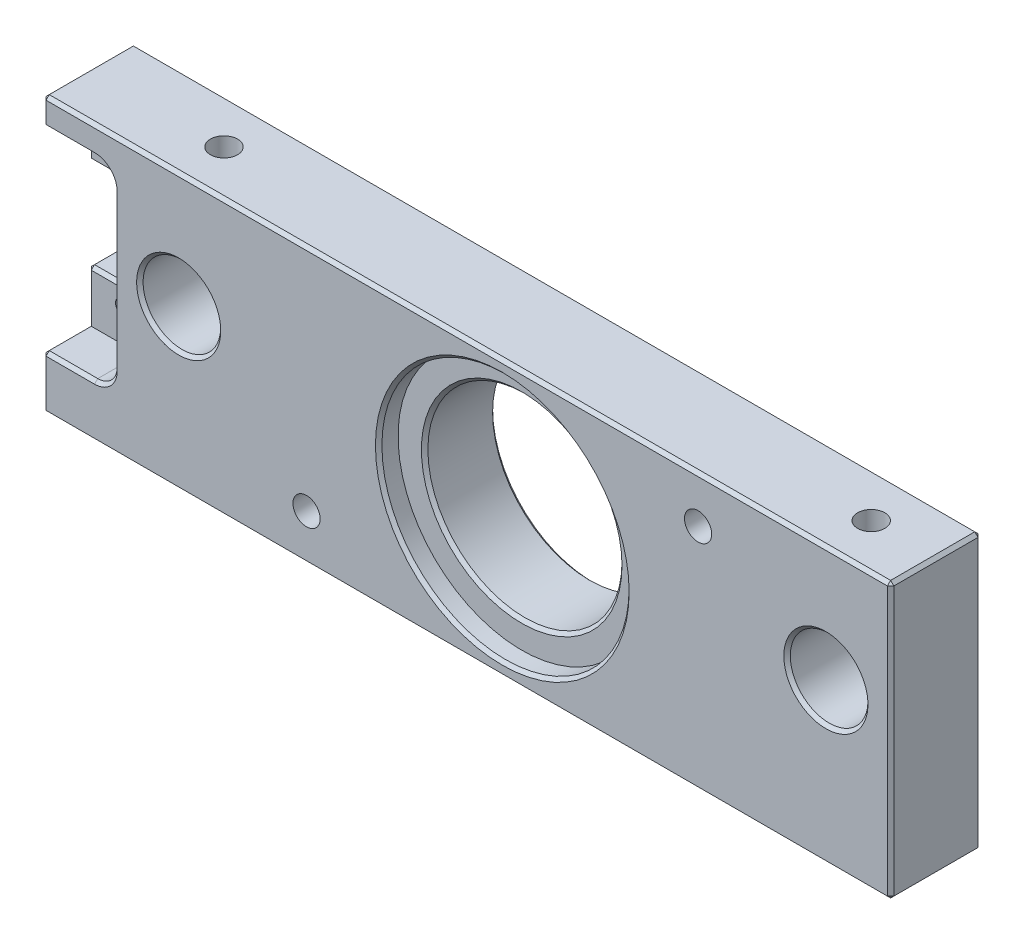
from build123d import *

# Parameters (mm, degrees)
SKETCH1_W                      = 120
SKETCH1_H                      = 42.5
BOSS_EXTRUDE1_DEPTH            = 7
SKETCH2_R                      = 19.1
CUT_EXTRUDE1_DEPTH             = 3
SKETCH3_R                      = 15
CUT_EXTRUDE2_DEPTH             = 65.595375221
M5X0_8_TAPPED_HOLE3_D          = 4.2
M5X0_8_TAPPED_HOLE3_DEPTH      = 14
M5X0_8_TAPPED_HOLE3_TIP        = 1.2618073
SKETCH5_R                      = 6
CUT_EXTRUDE4_DEPTH             = 66.173326599
M5X0_8_TAPPED_HOLE2_AT_2_COUNT = 2
M5X0_8_TAPPED_HOLE2_AT_2_PITCH = 28
SKETCH6_R                      = 1.25
CUT_EXTRUDE5_DEPTH             = 10
M5X0_8_TAPPED_HOLE1_REACH      = 75.86
M5X0_8_TAPPED_HOLE1_BORE_R     = 2.1
SKETCH16_W                     = 14
SKETCH16_H                     = 42.5
BOSS_EXTRUDE2_DEPTH            = 11
SKETCH17_W                     = 11
SKETCH17_H                     = 30
CUT_EXTRUDE6_DEPTH             = 7
M3X0_5_TAPPED_HOLE1_D          = 2.5
SKETCH21_W                     = 10
SKETCH21_H                     = 14
CUT_EXTRUDE7_DEPTH             = 75.441671835
FILLET1_R                      = 3
CHAMFER1_SIZE                  = 0.5


with BuildPart() as part:
    # Sketch1 → Boss-Extrude1 (new, symmetric)
    with BuildSketch(Plane.XY):
        Rectangle(SKETCH1_W, SKETCH1_H)
    extrude(amount=BOSS_EXTRUDE1_DEPTH, both=True)

    # Sketch2 → Cut-Extrude1 (cut)
    with BuildSketch(Plane.XY.offset(7)):
        Circle(SKETCH2_R)
    extrude(amount=-CUT_EXTRUDE1_DEPTH, mode=Mode.SUBTRACT)

    # Sketch3 → Cut-Extrude2 (cut, through all)
    with BuildSketch(Plane.XY.offset(4)):
        Circle(SKETCH3_R)
    extrude(amount=-CUT_EXTRUDE2_DEPTH, mode=Mode.SUBTRACT)

    # M5x0.8 Tapped Hole3
    with Locations(Plane.XY.offset(7)):
        with Locations((-30.248022392, -14.104884486), (30.248022392, 14.104884486)):
            Hole(M5X0_8_TAPPED_HOLE3_D / 2, depth=M5X0_8_TAPPED_HOLE3_DEPTH)
            with Locations((0, 0, -(M5X0_8_TAPPED_HOLE3_DEPTH + M5X0_8_TAPPED_HOLE3_TIP / 2))):  # 118° drill point
                Cone(0, M5X0_8_TAPPED_HOLE3_D / 2, M5X0_8_TAPPED_HOLE3_TIP, mode=Mode.SUBTRACT)

    # Sketch5 → Cut-Extrude4 (cut, through all)
    with BuildSketch(Plane.XY.offset(7)):
        with Locations((-50, 3.4)):
            Circle(SKETCH5_R)
        with Locations((50, 3.4)):
            Circle(SKETCH5_R)
    extrude(amount=-CUT_EXTRUDE4_DEPTH, mode=Mode.SUBTRACT)

    # Sketch10 → M5x0.8 Tapped Hole2 (revolve, cut)
    with BuildSketch(Plane(origin=(-50, -21.25, 0), x_dir=(0, 0, -1), z_dir=(1, 0, 0))):
        Polygon((0, 0), (0, 15.2618073), (2.1, 14), (2.1, 0), align=None)
    m5x0_8_tapped_hole2 = revolve(axis=Axis((-50, -27.6, 0), (0, 1, 0)), mode=Mode.SUBTRACT)

    # M5x0.8 Tapped Hole2 at 2: M5x0.8 Tapped Hole2 ×2
    with Locations(*[(i * M5X0_8_TAPPED_HOLE2_AT_2_PITCH, 0, 0) for i in range(1, M5X0_8_TAPPED_HOLE2_AT_2_COUNT)]):
        add(m5x0_8_tapped_hole2, mode=Mode.SUBTRACT)

    # Sketch6 → Cut-Extrude5 (cut)
    with BuildSketch(Plane.XZ.offset(21.25)):
        with Locations(Location((-36, 0, 0), (0, 0, 270))):
            Circle(SKETCH6_R)
    cut_extrude5 = extrude(amount=-CUT_EXTRUDE5_DEPTH, mode=Mode.SUBTRACT)

    # Mirror1: M5x0.8 Tapped Hole2, Cut-Extrude5 across plane
    add(m5x0_8_tapped_hole2.mirror(Plane(origin=(0, 0, 0), x_dir=(0, 0, 1), z_dir=(1, 0, 0))), mode=Mode.SUBTRACT)
    add(cut_extrude5.mirror(Plane(origin=(0, 0, 0), x_dir=(0, 0, 1), z_dir=(1, 0, 0))), mode=Mode.SUBTRACT)

    # Mirror1 copy 1 sketch → Mirror1 copy 1 (revolve, cut)
    with BuildSketch(Plane(origin=(22, -21.25, 0), x_dir=(0, 0, -1), z_dir=(-1, 0, 0))):
        Polygon((0, 0), (0, -15.2618073), (2.1, -14), (2.1, 0), align=None)
    revolve(axis=Axis((22, -27.6, 0), (0, -1, 0)), mode=Mode.SUBTRACT)

    # M5x0.8 Tapped Hole1 bore → M5x0.8 Tapped Hole1 (cut, up to next)
    with BuildSketch(Plane(origin=(0, 21.25, 0), x_dir=(1, 0, 0), z_dir=(0, 1, 0)), mode=Mode.PRIVATE) as m5x0_8_tapped_hole1_sk1:
        with Locations((-50, 0)):
            Circle(M5X0_8_TAPPED_HOLE1_BORE_R)
    m5x0_8_tapped_hole1_tool1 = extrude(m5x0_8_tapped_hole1_sk1.sketch, amount=-M5X0_8_TAPPED_HOLE1_REACH, mode=Mode.PRIVATE) & part.part
    # M5x0.8 Tapped Hole1 bore → M5x0.8 Tapped Hole1 (cut, up to next)
    with BuildSketch(Plane(origin=(0, 21.25, 0), x_dir=(1, 0, 0), z_dir=(0, 1, 0)), mode=Mode.PRIVATE) as m5x0_8_tapped_hole1_sk2:
        with Locations((50, 0)):
            Circle(M5X0_8_TAPPED_HOLE1_BORE_R)
    m5x0_8_tapped_hole1_tool2 = extrude(m5x0_8_tapped_hole1_sk2.sketch, amount=-M5X0_8_TAPPED_HOLE1_REACH, mode=Mode.PRIVATE) & part.part
    add(m5x0_8_tapped_hole1_tool1.solids().sort_by_distance((-50, 21.25, 0))[0], mode=Mode.SUBTRACT)
    add(m5x0_8_tapped_hole1_tool2.solids().sort_by_distance((50, 21.25, 0))[0], mode=Mode.SUBTRACT)

    # Sketch16 → Boss-Extrude2 (add)
    with BuildSketch(Plane.ZY.offset(60)):
        Rectangle(SKETCH16_W, SKETCH16_H)
    extrude(amount=BOSS_EXTRUDE2_DEPTH)

    # Sketch17 → Cut-Extrude6 (cut)
    with BuildSketch(Plane.XY.offset(7)):
        with Locations((-65.5, 2)):
            Rectangle(SKETCH17_W, SKETCH17_H)
    extrude(amount=-CUT_EXTRUDE6_DEPTH, mode=Mode.SUBTRACT)

    # M3x0.5 Tapped Hole1 (through all)
    with Locations(Plane.XY):
        with Locations((-65.5, 12), (-65.5, -8)):
            Hole(M3X0_5_TAPPED_HOLE1_D / 2)

    # Sketch21 → Cut-Extrude7 (cut, through all)
    with BuildSketch(Plane.XY):
        with Locations((-66, 2)):
            Rectangle(SKETCH21_W, SKETCH21_H)
    extrude(amount=-CUT_EXTRUDE7_DEPTH, mode=Mode.SUBTRACT)

    # Fillet1
    fillet1_edges = [part.edges().sort_by_distance(p)[0] for p in [
        (-61, 9, -3.5),
        (-61, -5, -3.5),
        (-60, 17, 3.5),
        (-60, -13, 3.5),
    ]]
    fillet(fillet1_edges, radius=FILLET1_R)

    # Chamfer1
    chamfer1_edges = [part.edges().sort_by_distance(p)[0] for p in [
        (-71, -9, 0),
        (-71, -13.125, -7),
        (-71, -5, -3.5),
        (-71, 9, -3.5),
        (-67.5, -5, -7),
        (-67.5, -5, 0),
        (-5.5, -21.25, 7),
        (-61, 2, 0),
        (-61, 2, -7),
        (-67.5, 9, 0),
        (-67.5, 9, -7),
        (-60, 2, 7),
        (-67, 17, 7),
        (-61.878679656, -4.121320344, 0),
        (-61.878679656, -4.121320344, -7),
        (-61.878679656, 8.121320344, 0),
        (-61.878679656, 8.121320344, -7),
        (-60.878679656, -12.121320344, 7),
        (-19.1, 0, 7),
        (-60.878679656, 16.121320344, 7),
        (-15, 0, -7),
        (-15, 0, 4),
        (-56, 3.4, -7),
        (-56, 3.4, 7),
        (44, 3.4, -7),
        (44, 3.4, 7),
        (60, 0, 7),
        (-5.5, -21.25, -7),
        (-36, -21.25, 1.25),
        (-5.5, 21.25, -7),
        (60, 0, -7),
        (36, -21.25, 1.25),
        (-5.5, 21.25, 7),
        (60, -21.25, 0),
        (60, 21.25, 0),
        (-71, -17.125, 7),
        (-71, 21.25, 0),
        (-71, 15.125, -7),
        (-71, -21.25, 0),
        (-71, 19.125, 7),
        (-71, 13, 0),
        (-71, -13, 3.5),
        (-71, 17, 3.5),
        (-67, -13, 7),
    ]]
    chamfer(chamfer1_edges, length=CHAMFER1_SIZE)


solid = part.part
